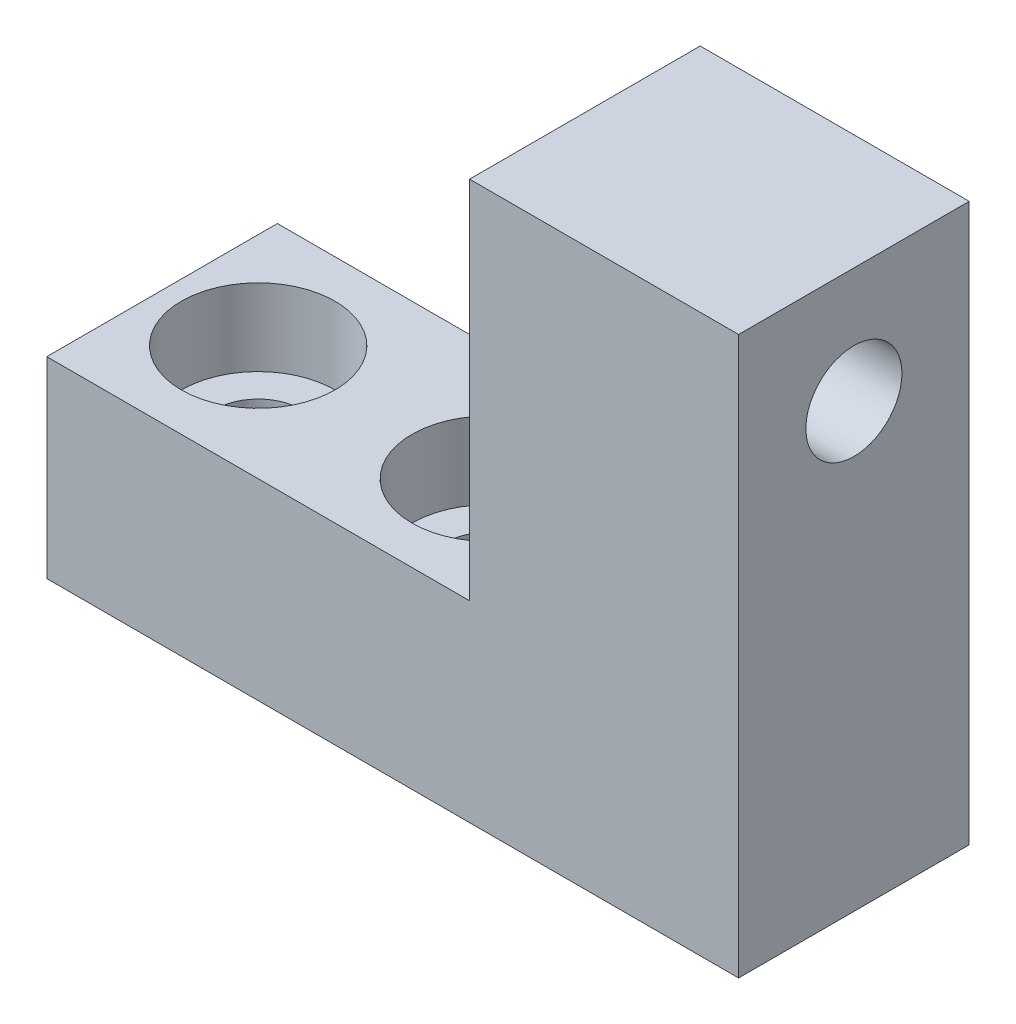
from build123d import *

# Parameters (mm, degrees)
SKETCH1_W           = 36
SKETCH1_H           = 10
BOSS_EXTRUDE1_DEPTH = 12
SKETCH2_W           = 14
SKETCH2_H           = 12
BOSS_EXTRUDE2_DEPTH = 19
SKETCH3_R           = 2.25
CUT_EXTRUDE1_DEPTH  = 11
SKETCH4_R           = 4
CUT_EXTRUDE2_DEPTH  = 4
M6_TAPPED_HOLE1_D   = 5


with BuildPart() as part:
    # Sketch1 → Boss-Extrude1 (new body)
    with BuildSketch(Plane.XY):
        with Locations((9.722605043, -1.956268222)):
            Rectangle(SKETCH1_W, SKETCH1_H)
    extrude(amount=BOSS_EXTRUDE1_DEPTH)

    # Sketch2 → Boss-Extrude2 (add)
    with BuildSketch(Plane(origin=(0, 3.043731778, 0), x_dir=(1, 0, 0), z_dir=(0, 1, 0))):
        with Locations((20.722605043, -6)):
            Rectangle(SKETCH2_W, SKETCH2_H)
    extrude(amount=BOSS_EXTRUDE2_DEPTH)

    # Sketch3 → Cut-Extrude1 (cut, through all)
    with BuildSketch(Plane(origin=(0, 3.043731778, 0), x_dir=(1, 0, 0), z_dir=(0, 1, 0))):
        with Locations((-3.277394957, -6)):
            Circle(SKETCH3_R)
        with Locations((8.722605043, -6)):
            Circle(SKETCH3_R)
    extrude(amount=-CUT_EXTRUDE1_DEPTH, mode=Mode.SUBTRACT)

    # Sketch4 → Cut-Extrude2 (cut)
    with BuildSketch(Plane(origin=(0, 3.043731778, 0), x_dir=(1, 0, 0), z_dir=(0, 1, 0))):
        with Locations((-3.277394957, -6)):
            Circle(SKETCH4_R)
        with Locations((8.722605043, -6)):
            Circle(SKETCH4_R)
    extrude(amount=-CUT_EXTRUDE2_DEPTH, mode=Mode.SUBTRACT)

    # M6 Tapped Hole1 (through all)
    with Locations(Plane(origin=(27.722605043, 0, 0), x_dir=(0, 0, -1), z_dir=(1, 0, 0))):
        with Locations((-6, 16.043731778)):
            Hole(M6_TAPPED_HOLE1_D / 2)


solid = part.part
